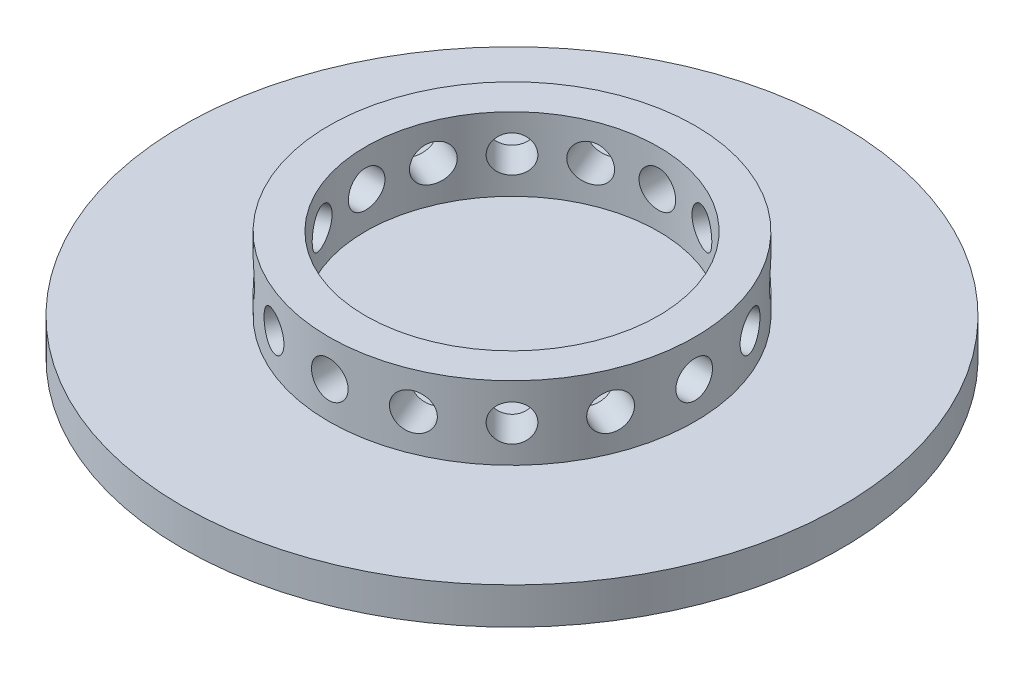
from build123d import *

# Parameters (mm, degrees)
CIRPATTERN1_COUNT = 16


with BuildPart() as part:
    # Sketch1 → Revolve1 (revolve)
    with BuildSketch(Plane.XY):
        Polygon((0, 0), (-52.0065, 0), (-52.0065, 2.54), (-55.5625, 2.54), (-55.5625, 0), (-57.15, 0), (-57.15, 6.35), (-31.75, 6.35), (-31.75, 19.05), (-25.4, 19.05), (-25.4, 6.35), (0, 6.35), align=None)
    revolve(axis=Axis((0, 6.35, 0), (0, -1, 0)))

    # Sketch3 → 1/4 (0.25) Diameter Hole1 (revolve, cut)
    with BuildSketch(Plane(origin=(31.75, 12.7, 0), x_dir=(0, 0, -1), z_dir=(0, 1, 0))):
        Polygon((0, 0), (0, 33.656732465), (3.175, 31.749), (3.175, 0), align=None)
    f_1_4_0_25_diameter_hole1 = revolve(axis=Axis((38.1, 12.7, 0), (-1, 0, 0)), mode=Mode.SUBTRACT)

    # CirPattern1: 1/4 (0.25) Diameter Hole1 ×16 about axis
    cirpattern1_axis = Axis((0, 6.35, 0), (0, 1, 0))
    for i in range(1, CIRPATTERN1_COUNT):
        add(f_1_4_0_25_diameter_hole1.rotate(cirpattern1_axis, i * 360 / CIRPATTERN1_COUNT), mode=Mode.SUBTRACT)


solid = part.part
